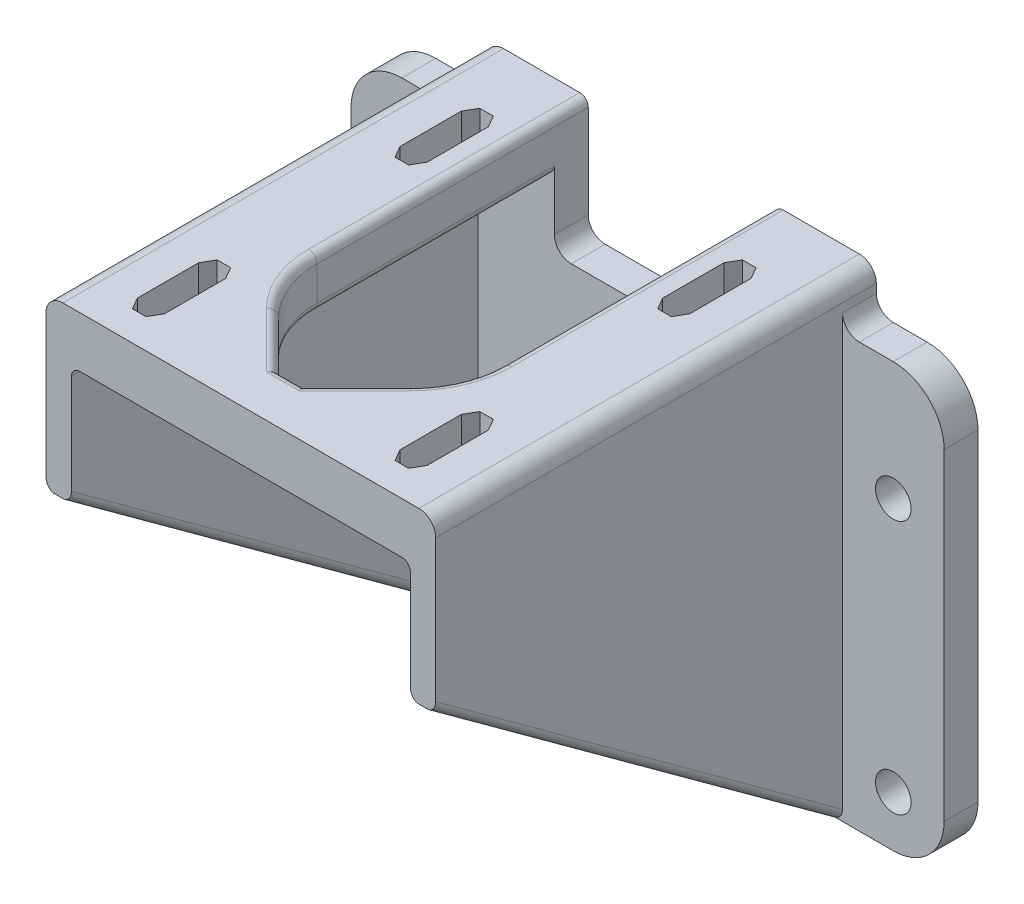
from build123d import *

# Parameters (mm, degrees)
SKETCH1_W                      = 70
SKETCH1_H                      = 50
BOSS_EXTRUDE1_DEPTH            = 4
BOSS_EXTRUDE2_DEPTH            = 52
CUT_EXTRUDE3_DEPTH             = 70.491006612
CUT_EXTRUDE3_DEPTH_BACK        = 70.491006612
FILLET1_R                      = 6
CUT_EXTRUDE6_DEPTH             = 84.390646958
SKETCH7_W                      = 22
SKETCH7_H                      = 9
CUT_EXTRUDE7_DEPTH             = 67.550732528
F_4_2_4_2_DIAMETER_HOLE1_D     = 4.2
F_4_2_4_2_DIAMETER_HOLE1_DEPTH = 4
F_4_2_4_2_DIAMETER_HOLE1_TIP   = 1.2618073
CUT_EXTRUDE8_REACH             = 68.551
BOSS_EXTRUDE3_DEPTH            = 6
FILLET2_R                      = 2
FILLET3_R                      = 1
FILLET4_R                      = 1


with BuildPart() as part:
    # Sketch1 → Boss-Extrude1 (new body)
    with BuildSketch(Plane.XY):
        Rectangle(SKETCH1_W, SKETCH1_H)
    extrude(amount=BOSS_EXTRUDE1_DEPTH)

    # Sketch2 → Boss-Extrude2 (add)
    with BuildSketch(Plane.XY):
        Polygon((-23, -25), (-20, -25), (-20, 24), (-11, 24), (-11, 30), (-23, 30), align=None)
        Polygon((11, 24), (11, 30), (23, 30), (23, -25), (20, -25), (20, 24), align=None)
    extrude(amount=BOSS_EXTRUDE2_DEPTH)

    # Sketch3 → Cut-Extrude3 (cut, two sides: drawn at the far end of the back side and taken through both)
    with BuildSketch(Plane.ZY.offset(-CUT_EXTRUDE3_DEPTH_BACK)):
        Polygon((178.049174714, 101.910856562), (52, 10), (4, -25), (-122.049174714, -116.910856562), (61.77253841, -369.00920599), (361.870887838, -150.187492865), align=None)
    extrude(amount=CUT_EXTRUDE3_DEPTH + CUT_EXTRUDE3_DEPTH_BACK, mode=Mode.SUBTRACT)

    # Fillet1
    fillet1_edges = [part.edges().sort_by_distance(p)[0] for p in [
        (35, -25, 2),
        (-35, -25, 2),
        (-35, 25, 2),
        (35, 25, 2),
    ]]
    fillet(fillet1_edges, radius=FILLET1_R)

    # Sketch6 → Cut-Extrude6 (cut, through all)
    with BuildSketch(Plane(origin=(0, 30, 0), x_dir=(1, 0, 0), z_dir=(0, 1, 0))):
        Polygon((-17.1, -47.114359354), (-17.1, -39.885640646), (-16.3, -38.5), (-14.7, -38.5), (-13.9, -39.885640646), (-13.9, -47.114359354), (-14.7, -48.5), (-16.3, -48.5), align=None)
        Polygon((16.3, -48.5), (17.1, -47.114359354), (17.1, -39.885640646), (16.3, -38.5), (14.7, -38.5), (13.9, -39.885640646), (13.9, -47.114359354), (14.7, -48.5), align=None)
        Polygon((17.1, -8.885640646), (17.1, -16.114359354), (16.3, -17.5), (14.7, -17.5), (13.9, -16.114359354), (13.9, -8.885640646), (14.7, -7.5), (16.3, -7.5), align=None)
        Polygon((-16.3, -7.5), (-17.1, -8.885640646), (-17.1, -16.114359354), (-16.3, -17.5), (-14.7, -17.5), (-13.9, -16.114359354), (-13.9, -8.885640646), (-14.7, -7.5), align=None)
    extrude(amount=-CUT_EXTRUDE6_DEPTH, mode=Mode.SUBTRACT)

    # Sketch7 → Cut-Extrude7 (cut, through all)
    with BuildSketch(Plane.XY.offset(4)):
        with Locations((0, 20.5)):
            Rectangle(SKETCH7_W, SKETCH7_H)
    extrude(amount=-CUT_EXTRUDE7_DEPTH, mode=Mode.SUBTRACT)

    # Ø4.2 (4.2) Diameter Hole1
    with Locations(Plane.XY.offset(4)):
        with Locations((-29, -19), (-29, 11), (29, -19), (29, 11)):
            Hole(F_4_2_4_2_DIAMETER_HOLE1_D / 2, depth=F_4_2_4_2_DIAMETER_HOLE1_DEPTH)
            with Locations((0, 0, -(F_4_2_4_2_DIAMETER_HOLE1_DEPTH + F_4_2_4_2_DIAMETER_HOLE1_TIP / 2))):  # 118° drill point
                Cone(0, F_4_2_4_2_DIAMETER_HOLE1_D / 2, F_4_2_4_2_DIAMETER_HOLE1_TIP, mode=Mode.SUBTRACT)

    # Sketch10 → Cut-Extrude8 (cut, up to next)
    with BuildSketch(Plane.XY.offset(4), mode=Mode.PRIVATE) as cut_extrude8_sk1:
        with BuildLine():
            Line((1.414213562, 5.899494937), (9.899494937, -2.585786438))
            ThreePointArc((9.899494937, -2.585786438), (10.485281374, -4), (9.899494937, -5.414213562))
            Line((9.899494937, -5.414213562), (1.414213562, -13.899494937))
            ThreePointArc((1.414213562, -13.899494937), (0, -14.485281374), (-1.414213562, -13.899494937))
            Line((-1.414213562, -13.899494937), (-9.899494937, -5.414213562))
            ThreePointArc((-9.899494937, -5.414213562), (-10.485281374, -4), (-9.899494937, -2.585786438))
            Line((-9.899494937, -2.585786438), (-1.414213562, 5.899494937))
            ThreePointArc((-1.414213562, 5.899494937), (0, 6.485281374), (1.414213562, 5.899494937))
        make_face()
    cut_extrude8_tool1 = extrude(cut_extrude8_sk1.sketch, amount=-CUT_EXTRUDE8_REACH, mode=Mode.PRIVATE) & part.part
    add(cut_extrude8_tool1.solids().sort_by_distance((0, -4, 4))[0], mode=Mode.SUBTRACT)

    # Sketch11 → Boss-Extrude3 (add)
    with BuildSketch(Plane(origin=(0, 30, 0), x_dir=(1, 0, 0), z_dir=(0, 1, 0))):
        with BuildLine():
            Line((-1.5, -46.056349186), (-7.778174593, -39.778174593))
            ThreePointArc((-7.778174593, -39.778174593), (-10.162674858, -36.209517756), (-11, -32))
            Line((-11, -32), (-11, -52))
            Line((-11, -52), (11, -52))
            Line((11, -52), (11, -32))
            ThreePointArc((11, -32), (10.162674858, -36.209517756), (7.778174593, -39.778174593))
            Line((7.778174593, -39.778174593), (1.5, -46.056349186))
            Line((1.5, -46.056349186), (-1.5, -46.056349186))
        make_face()
    extrude(amount=-BOSS_EXTRUDE3_DEPTH)

    # Fillet2
    fillet2_edges = [part.edges().sort_by_distance(p)[0] for p in [
        (-23, 25, 2),
        (-23, 30, 26),
        (-11, 16, 2),
        (11, 16, 2),
        (23, 25, 2),
        (23, 30, 26),
    ]]
    fillet(fillet2_edges, radius=FILLET2_R)

    # Fillet3
    fillet3_edges = [part.edges().sort_by_distance(p)[0] for p in [
        (11, 30, 16),
        (-11, 30, 16),
        (-10.162674858, 30, 36.209517756),
        (10.162674858, 30, 36.209517756),
        (4.639087297, 30, 42.91726189),
        (0, 30, 46.056349186),
        (-4.639087297, 30, 42.91726189),
    ]]
    fillet(fillet3_edges, radius=FILLET3_R)

    # Fillet4
    fillet4_edges = [part.edges().sort_by_distance(p)[0] for p in [
        (-20, 24, 28),
        (11, 24, 18),
        (-11, 24, 18),
        (-10.162674858, 24, 36.209517756),
        (-4.639087297, 24, 42.91726189),
        (0, 24, 46.056349186),
        (4.639087297, 24, 42.91726189),
        (10.162674858, 24, 36.209517756),
        (20, 24, 28),
        (-23, -7.5, 28),
        (-20, -7.5, 28),
        (20, -7.5, 28),
        (23, -7.5, 28),
    ]]
    fillet(fillet4_edges, radius=FILLET4_R)


solid = part.part
